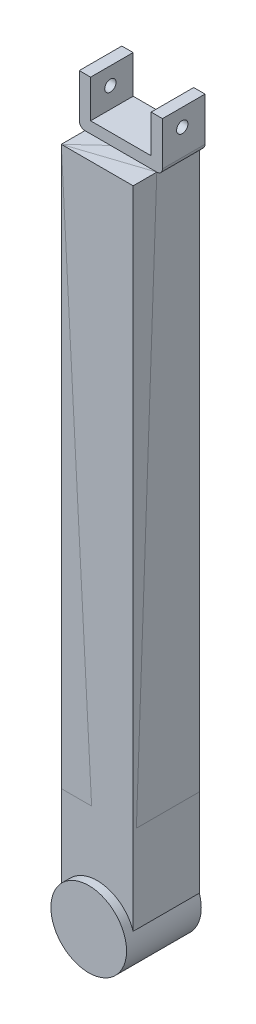
from build123d import *

# Parameters (mm, degrees)
SKETCH1_W                = 38
SKETCH1_H                = 35
BOSS_EXTRUDE1_DEPTH      = 295
BOSS_EXTRUDE3_DEPTH      = 5
BOSS_EXTRUDE3_DEPTH_BACK = 17.5
SKETCH1_3_W              = 38
SKETCH1_3_H              = 35
BOSS_EXTRUDE6_DEPTH      = 348.59
CUT_EXTRUDE1_START       = -6
SKETCH3_R                = 3
CUT_EXTRUDE1_DEPTH       = 6
SKETCH5_R                = 20
BOSS_EXTRUDE8_DEPTH      = 22
BOSS_EXTRUDE8_DEPTH_BACK = 17.5
SKETCH8_R                = 5
CUT_EXTRUDE2_DEPTH       = 10


with BuildPart() as part:
    # Sketch1 → Boss-Extrude1 (new body)
    with BuildSketch(Plane(origin=(0, 0, 0), x_dir=(1, 0, 0), z_dir=(0, 1, 0))):
        Rectangle(SKETCH1_W, SKETCH1_H)
    extrude(amount=-BOSS_EXTRUDE1_DEPTH)


with BuildPart() as body_2:
    # Sketch2 → Boss-Extrude3 (new body, two sides)
    with BuildSketch(Plane.XY) as boss_extrude3_sk:
        with BuildLine():
            Line((-19, 0), (19, 0))
            ThreePointArc((19, 0), (21.121320344, 0.878679656), (22, 3))
            Line((22, 3), (22, 26))
            Line((22, 26), (16, 26))
            Line((16, 26), (16, 6))
            Line((16, 6), (-16, 6))
            Line((-16, 6), (-16, 26))
            Line((-16, 26), (-22, 26))
            Line((-22, 26), (-22, 3))
            ThreePointArc((-22, 3), (-21.121320344, 0.878679656), (-19, 0))
        make_face()
    extrude(amount=BOSS_EXTRUDE3_DEPTH)
    extrude(boss_extrude3_sk.sketch, amount=-BOSS_EXTRUDE3_DEPTH_BACK)

    # Sketch1_3 → Boss-Extrude6 (add)
    with BuildSketch(Plane(origin=(0, 0, 0), x_dir=(1, 0, 0), z_dir=(0, 1, 0))):
        Rectangle(SKETCH1_3_W, SKETCH1_3_H)
    extrude(amount=-BOSS_EXTRUDE6_DEPTH)

    # Sketch3 → Cut-Extrude1 (cut)
    with BuildSketch(Plane.ZY.offset(-16).offset(CUT_EXTRUDE1_START)):
        with Locations((-5.46063237, 16.89632523)):
            Circle(SKETCH3_R)
    cut_extrude1 = extrude(amount=CUT_EXTRUDE1_DEPTH, mode=Mode.SUBTRACT)

    # Mirror1: Cut-Extrude1 across plane
    add(cut_extrude1.mirror(Plane(origin=(0, 0, 0), x_dir=(0, 0, 1), z_dir=(1, 0, 0))), mode=Mode.SUBTRACT)

    # Sketch5 → Boss-Extrude8 (add, two sides)
    with BuildSketch(Plane.XY) as boss_extrude8_sk:
        with Locations((0, -347.60367477)):
            Circle(SKETCH5_R)
    extrude(amount=BOSS_EXTRUDE8_DEPTH)
    extrude(boss_extrude8_sk.sketch, amount=-BOSS_EXTRUDE8_DEPTH_BACK)

    # Sketch8 → Cut-Extrude2 (cut)
    with BuildSketch(Plane.ZY.offset(19)):
        with Locations((-5.46063237, -85)):
            Circle(SKETCH8_R)
    extrude(amount=-CUT_EXTRUDE2_DEPTH, mode=Mode.SUBTRACT)


solid = Compound([part.part, body_2.part])
